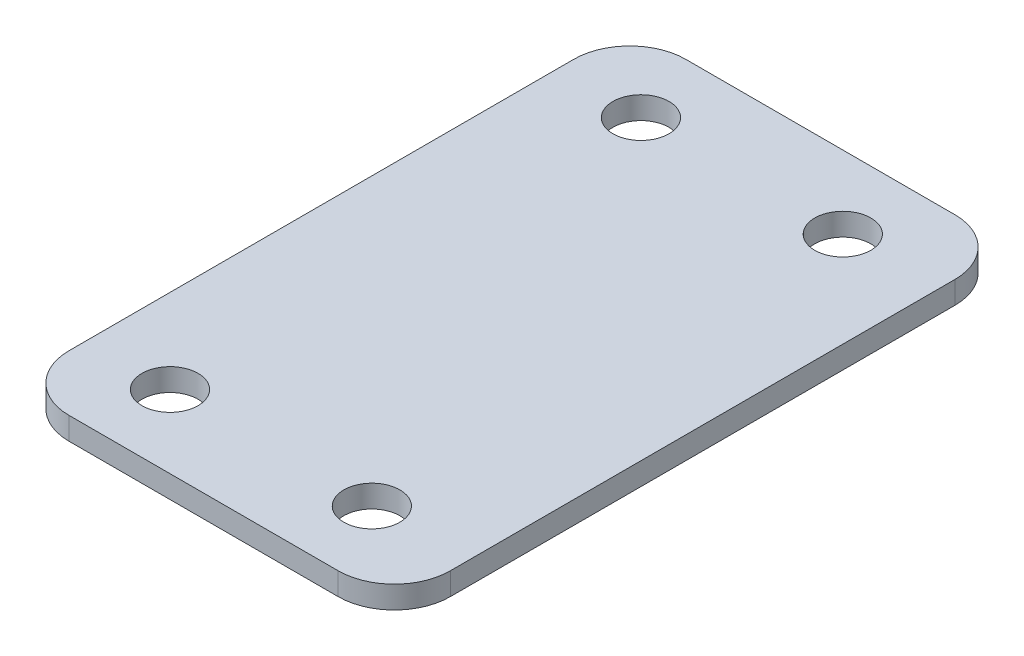
from build123d import *

# Parameters (mm, degrees)
SKETCH1_W           = 40
SKETCH1_H           = 55
BOSS_EXTRUDE1_DEPTH = 2
SKETCH3_R           = 2.5
CUT_EXTRUDE1_DEPTH  = 2
SKETCH4_W           = 6
SKETCH4_H           = 55
CUT_EXTRUDE2_DEPTH  = 2
FILLET1_R           = 5


with BuildPart() as part:
    # Sketch1 → Boss-Extrude1 (new body)
    with BuildSketch(Plane(origin=(0, 0, 0), x_dir=(1, 0, 0), z_dir=(0, 1, 0))):
        Rectangle(SKETCH1_W, SKETCH1_H)
    extrude(amount=BOSS_EXTRUDE1_DEPTH)

    # Sketch3 → Cut-Extrude1 (cut)
    with BuildSketch(Plane(origin=(0, 2, 0), x_dir=(1, 0, 0), z_dir=(0, 1, 0))):
        with Locations((-12.5, 21)):
            Circle(SKETCH3_R)
        with Locations((-12.5, -21)):
            Circle(SKETCH3_R)
        with Locations((5.5, 21)):
            Circle(SKETCH3_R)
        with Locations((5.5, -21)):
            Circle(SKETCH3_R)
    extrude(amount=-CUT_EXTRUDE1_DEPTH, mode=Mode.SUBTRACT)

    # Sketch4 → Cut-Extrude2 (cut)
    with BuildSketch(Plane(origin=(0, 2, 0), x_dir=(1, 0, 0), z_dir=(0, 1, 0))):
        with Locations((17, 0)):
            Rectangle(SKETCH4_W, SKETCH4_H)
    extrude(amount=-CUT_EXTRUDE2_DEPTH, mode=Mode.SUBTRACT)

    # Fillet1
    fillet1_edges = [part.edges().sort_by_distance(p)[0] for p in [
        (14, 1, 27.5),
        (14, 1, -27.5),
        (-20, 1, -27.5),
        (-20, 1, 27.5),
    ]]
    fillet(fillet1_edges, radius=FILLET1_R)


solid = part.part
